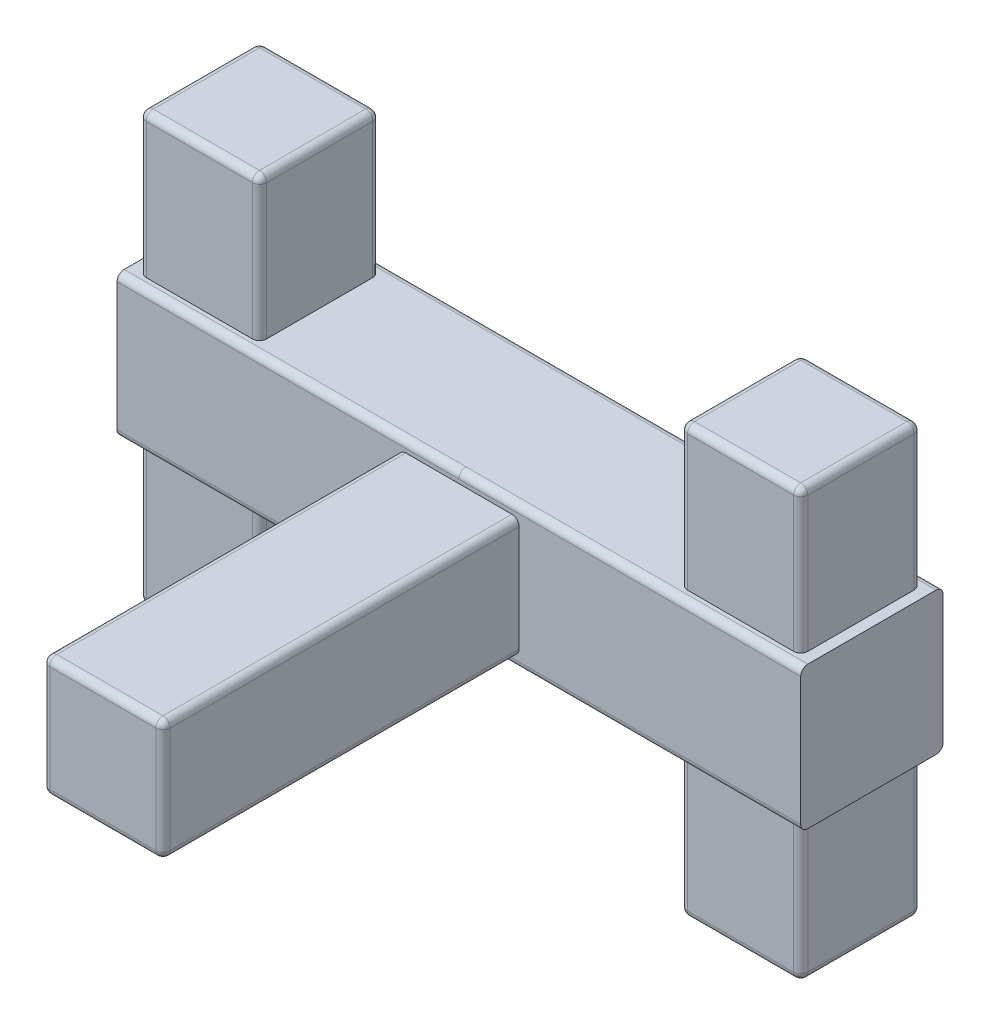
from build123d import *

# Parameters (mm, degrees)
SKETCH1_W            = 48
SKETCH1_H            = 20
BOSS_EXTRUDE3_DEPTH  = 20
BOSS_EXTRUDE4_START  = -20
SKETCH1_6_W          = 16.9
SKETCH1_6_H          = 16.9
BOSS_EXTRUDE4_DEPTH  = 60
FILLET2_R            = 1
FILLET2_OF_MIRROR1_R = 1
SKETCH3_W            = 16.9
SKETCH3_H            = 16.9
BOSS_EXTRUDE5_DEPTH  = 50
FILLET3_R            = 1


with BuildPart() as part:
    # Sketch1 → Boss-Extrude3 (new body)
    with BuildSketch(Plane(origin=(0, 0, 0), x_dir=(1, 0, 0), z_dir=(0, 1, 0))):
        with Locations((-24, 0)):
            Rectangle(SKETCH1_W, SKETCH1_H)
    boss_extrude3 = extrude(amount=BOSS_EXTRUDE3_DEPTH)

    # Sketch1_6 → Boss-Extrude4 (add)
    with BuildSketch(Plane(origin=(0, 0, 0), x_dir=(1, 0, 0), z_dir=(0, 1, 0)).offset(BOSS_EXTRUDE4_START)):
        with Locations((-38, 0)):
            Rectangle(SKETCH1_6_W, SKETCH1_6_H)
    boss_extrude4 = extrude(amount=BOSS_EXTRUDE4_DEPTH)

    # Fillet2
    fillet2_edges = [part.edges().sort_by_distance(p)[0] for p in [
        (-29.55, 30, -8.45),
        (-46.45, 30, 8.45),
        (-46.45, 30, -8.45),
        (-46.45, 40, 0),
        (-29.55, 40, 0),
        (-38, 40, -8.45),
        (-38, 40, 8.45),
        (-29.55, 30, 8.45),
        (-29.55, -10, -8.45),
        (-29.55, -10, 8.45),
        (-29.55, -20, 0),
        (-38, -20, -8.45),
        (-38, -20, 8.45),
        (-46.45, -20, 0),
        (-46.45, -10, -8.45),
        (-46.45, -10, 8.45),
        (-24, 20, -10),
        (-24, 0, -10),
        (-24, 0, 10),
        (-24, 20, 10),
    ]]
    fillet(fillet2_edges, radius=FILLET2_R)

    # Mirror1: Boss-Extrude3, Boss-Extrude4 across plane
    add(boss_extrude3.mirror(Plane(origin=(0, 20, 0), x_dir=(0, 0, 1), z_dir=(1, 0, 0))))
    add(boss_extrude4.mirror(Plane(origin=(0, 20, 0), x_dir=(0, 0, 1), z_dir=(1, 0, 0))))

    # Fillet2 of Mirror1
    fillet2_of_mirror1_edges = [part.edges().sort_by_distance(p)[0] for p in [
        (29.55, 30, -8.45),
        (46.45, 30, 8.45),
        (46.45, 30, -8.45),
        (46.45, 40, 0),
        (29.55, 40, 0),
        (38, 40, -8.45),
        (38, 40, 8.45),
        (29.55, 30, 8.45),
        (29.55, -10, -8.45),
        (29.55, -10, 8.45),
        (29.55, -20, 0),
        (38, -20, -8.45),
        (38, -20, 8.45),
        (46.45, -20, 0),
        (46.45, -10, -8.45),
        (46.45, -10, 8.45),
        (24, 20, -10),
        (24, 0, -10),
        (24, 0, 10),
        (24, 20, 10),
    ]]
    fillet(fillet2_of_mirror1_edges, radius=FILLET2_OF_MIRROR1_R)

    # Sketch3 → Boss-Extrude5 (add)
    with BuildSketch(Plane.XY.offset(10)):
        with Locations((0, 10)):
            Rectangle(SKETCH3_W, SKETCH3_H)
    extrude(amount=BOSS_EXTRUDE5_DEPTH)

    # Fillet3
    fillet3_edges = [part.edges().sort_by_distance(p)[0] for p in [
        (8.45, 1.55, 35),
        (-8.45, 1.55, 35),
        (0, 1.55, 60),
        (-8.45, 10, 60),
        (8.45, 10, 60),
        (0, 18.45, 60),
        (8.45, 18.45, 35),
        (-8.45, 18.45, 35),
    ]]
    fillet(fillet3_edges, radius=FILLET3_R)


solid = part.part
